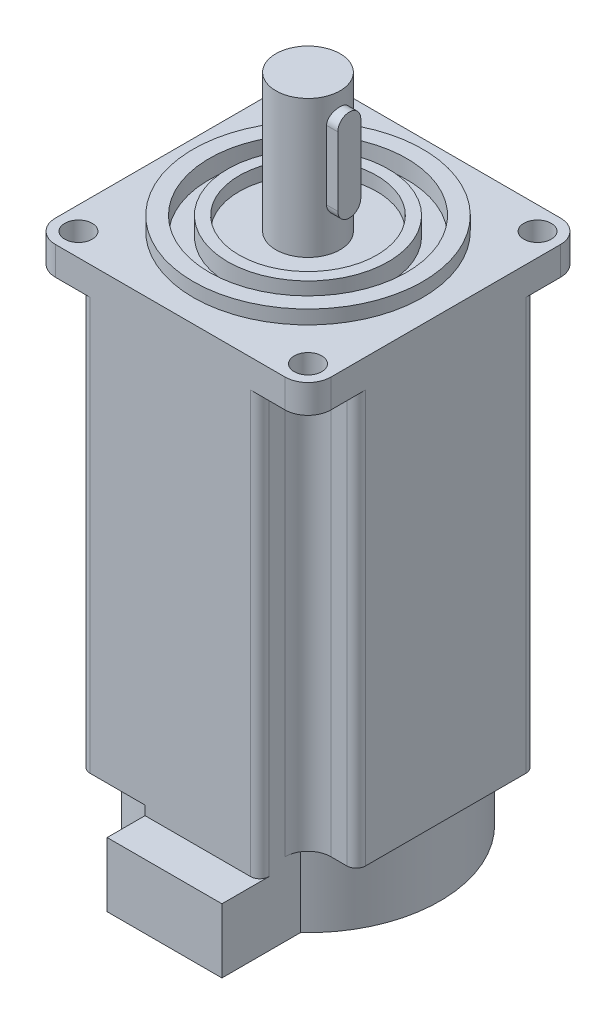
from build123d import *

# Parameters (mm, degrees)
SKETCH_2_W               = 60
SKETCH_2_H               = 60
EXTRUDE_1_DEPTH          = 96
SKETCH_3_W               = 10.5
SKETCH_3_H               = 10.5
CUT_EXTRUDE_1_DEPTH      = 97
PATTERN_CIRCULAR_1_COUNT = 4
SKETCH_4_W               = 60
SKETCH_4_H               = 60
EXTRUDE_2_DEPTH          = 6.2
SKETCH_5_R               = 25
EXTRUDE_3_DEPTH          = 3
SKETCH_8_R               = 21.5
SKETCH_8_R_2             = 17.5
CUT_EXTRUDE_3_DEPTH      = 4
SKETCH_9_R               = 15
CUT_EXTRUDE_4_DEPTH      = 3
SKETCH_10_R              = 7
EXTRUDE_5_DEPTH          = 30
FILLET_1_R               = 5
FILLET_2_R               = 2
FILLET_3_R               = 5
SKETCH_13_R              = 28.75
EXTRUDE_6_DEPTH          = 16
EXTRUDE_START            = 16
SKETCH_14_W              = 25
SKETCH_14_H              = 17.123890562
EXTRUDE_7_DEPTH          = 14
EXTRUDE_8_DEPTH          = 2
HOLE_WIZARD_6_0_6_1_D    = 6
CUT_EXTRUDE_5_DEPTH      = 3
EXTRUDE_9_DEPTH          = 5


with BuildPart() as part:
    # 草圖2 → 填料-伸長1 (new body)
    with BuildSketch(Plane(origin=(0, 0, 0), x_dir=(1, 0, 0), z_dir=(0, 1, 0))):
        Rectangle(SKETCH_2_W, SKETCH_2_H)
    extrude(amount=-EXTRUDE_1_DEPTH)

    # 草圖3 → 除料-伸長1 (cut, through all)
    with BuildSketch(Plane(origin=(0, 0, 0), x_dir=(1, 0, 0), z_dir=(0, 1, 0))):
        with Locations((-24.75, -24.75)):
            Rectangle(SKETCH_3_W, SKETCH_3_H)
    cut_extrude_1 = extrude(amount=-CUT_EXTRUDE_1_DEPTH, mode=Mode.SUBTRACT)

    # 環狀複製排列1: 除料-伸長1 ×4 about axis
    pattern_circular_1_axis = Axis((0, 0, 0), (0, 1, 0))
    for i in range(1, PATTERN_CIRCULAR_1_COUNT):
        add(cut_extrude_1.rotate(pattern_circular_1_axis, i * 360 / PATTERN_CIRCULAR_1_COUNT), mode=Mode.SUBTRACT)

    # 草圖4 → 填料-伸長2 (add)
    with BuildSketch(Plane(origin=(0, 0, 0), x_dir=(1, 0, 0), z_dir=(0, 1, 0))):
        Rectangle(SKETCH_4_W, SKETCH_4_H)
    extrude(amount=-EXTRUDE_2_DEPTH)

    # 草圖5 → 填料-伸長3 (add)
    with BuildSketch(Plane(origin=(0, 0, 0), x_dir=(1, 0, 0), z_dir=(0, 1, 0))):
        Circle(SKETCH_5_R)
    extrude(amount=EXTRUDE_3_DEPTH)

    # 草圖8 → 除料-伸長3 (cut)
    with BuildSketch(Plane(origin=(0, 3, 0), x_dir=(1, 0, 0), z_dir=(0, 1, 0))):
        Circle(SKETCH_8_R)
        Circle(SKETCH_8_R_2, mode=Mode.SUBTRACT)
    extrude(amount=-CUT_EXTRUDE_3_DEPTH, mode=Mode.SUBTRACT)

    # 草圖9 → 除料-伸長4 (cut)
    with BuildSketch(Plane(origin=(0, 3, 0), x_dir=(1, 0, 0), z_dir=(0, 1, 0))):
        Circle(SKETCH_9_R)
    extrude(amount=-CUT_EXTRUDE_4_DEPTH, mode=Mode.SUBTRACT)

    # 草圖10 → 填料-伸長5 (add)
    with BuildSketch(Plane(origin=(0, 0, 0), x_dir=(1, 0, 0), z_dir=(0, 1, 0))):
        Circle(SKETCH_10_R)
    extrude(amount=EXTRUDE_5_DEPTH)

    # 圓角1
    fillet_1_edges = [part.edges().sort_by_distance(p)[0] for p in [
        (-19.5, -51.1, 19.5),
        (-19.5, -51.1, -19.5),
        (19.5, -51.1, -19.5),
        (19.5, -51.1, 19.5),
    ]]
    fillet(fillet_1_edges, radius=FILLET_1_R)

    # 圓角2
    fillet_2_edges = [part.edges().sort_by_distance(p)[0] for p in [
        (-30, -51.1, 19.5),
        (-19.5, -51.1, 30),
        (-19.5, -51.1, -30),
        (-30, -51.1, -19.5),
        (30, -51.1, -19.5),
        (19.5, -51.1, -30),
        (19.5, -51.1, 30),
        (30, -51.1, 19.5),
    ]]
    fillet(fillet_2_edges, radius=FILLET_2_R)

    # 圓角3
    fillet_3_edges = [part.edges().sort_by_distance(p)[0] for p in [
        (30, -3.1, 30),
        (30, -3.1, -30),
        (-30, -3.1, -30),
        (-30, -3.1, 30),
    ]]
    fillet(fillet_3_edges, radius=FILLET_3_R)

    # 草圖13 → 填料-伸長6 (add)
    with BuildSketch(Plane.XZ.offset(96)):
        Circle(SKETCH_13_R)
    extrude(amount=EXTRUDE_6_DEPTH)

    # 草圖14 → 填料-伸長7 (add)
    with BuildSketch(Plane.XZ.offset(96).offset(EXTRUDE_START)):
        with Locations((7, 29.688054719)):
            Rectangle(SKETCH_14_W, SKETCH_14_H)
    extrude(amount=-EXTRUDE_7_DEPTH)

    # 草圖15 → 填料-伸長8 (add)
    with BuildSketch(Plane(origin=(0, -98, 0), x_dir=(1, 0, 0), z_dir=(0, 1, 0))):
        with BuildLine():
            Line((-5.5, -30), (17.5, -30))
            ThreePointArc((17.5, -30), (18.914213562, -29.414213562), (19.5, -28))
            Line((19.5, -28), (19.5, -21.126109438))
            ThreePointArc((19.5, -21.126109438), (7.847121001, -27.658365678), (-5.5, -28.21900955))
            Line((-5.5, -28.21900955), (-5.5, -30))
        make_face()
    extrude(amount=EXTRUDE_8_DEPTH)

    # Ø6.0 (6) 直徑孔1 (through all)
    with Locations(Plane(origin=(0, 0, 0), x_dir=(1, 0, 0), z_dir=(0, 1, 0))):
        with Locations((-25, 25), (25, 25), (25, -25), (-25, -25)):
            Hole(HOLE_WIZARD_6_0_6_1_D / 2)

    # 草圖20 → 除料-伸長5 (cut)
    with BuildSketch(Plane(origin=(7, 0, 0), x_dir=(0, 0, -1), z_dir=(1, 0, 0))):
        with BuildLine():
            Line((-2.5, 24.5), (-2.5, 9.5))
            ThreePointArc((-2.5, 9.5), (0, 7), (2.5, 9.5))
            Line((2.5, 9.5), (2.5, 24.5))
            ThreePointArc((2.5, 24.5), (0, 27), (-2.5, 24.5))
        make_face()
    extrude(amount=-CUT_EXTRUDE_5_DEPTH, mode=Mode.SUBTRACT)

    # 草圖21 → 填料-伸長9 (add)
    with BuildSketch(Plane(origin=(4, 0, 0), x_dir=(0, 0, -1), z_dir=(1, 0, 0))):
        with BuildLine():
            Line((-2.5, 24.5), (-2.5, 9.5))
            ThreePointArc((-2.5, 9.5), (0, 7), (2.5, 9.5))
            Line((2.5, 9.5), (2.5, 24.5))
            ThreePointArc((2.5, 24.5), (0, 27), (-2.5, 24.5))
        make_face()
    extrude(amount=EXTRUDE_9_DEPTH)


solid = part.part
